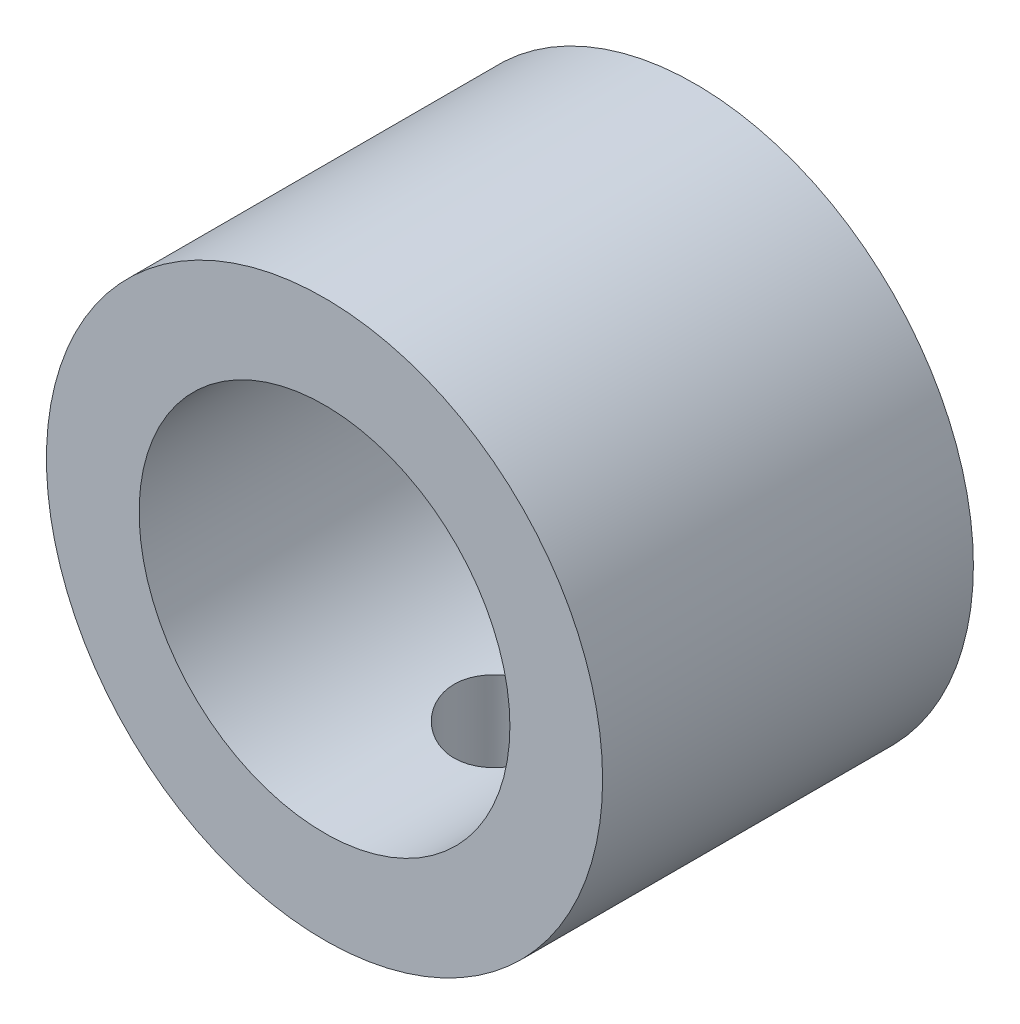
from build123d import *

# Parameters (mm, degrees)
SKETCH1_R           = 7.5
SKETCH1_R_2         = 5
BOSS_EXTRUDE4_DEPTH = 5
CUT_EXTRUDE2_REACH  = 9.5
SKETCH3_R           = 1.5


with BuildPart() as part:
    # Sketch1 → Boss-Extrude4 (new body, symmetric)
    with BuildSketch(Plane.XY):
        Circle(SKETCH1_R)
        Circle(SKETCH1_R_2, mode=Mode.SUBTRACT)
    extrude(amount=BOSS_EXTRUDE4_DEPTH, both=True)

    # Sketch3 → Cut-Extrude2 (cut, up to next)
    with BuildSketch(Plane(origin=(0, 0, 0), x_dir=(1, 0, 0), z_dir=(0, 1, 0)), mode=Mode.PRIVATE) as cut_extrude2_sk1:
        Circle(SKETCH3_R)
    cut_extrude2_tool1 = extrude(cut_extrude2_sk1.sketch, amount=-CUT_EXTRUDE2_REACH, mode=Mode.PRIVATE) & part.part
    add(cut_extrude2_tool1.solids().sort_by_distance((0, 0, 0))[0], mode=Mode.SUBTRACT)


solid = part.part
